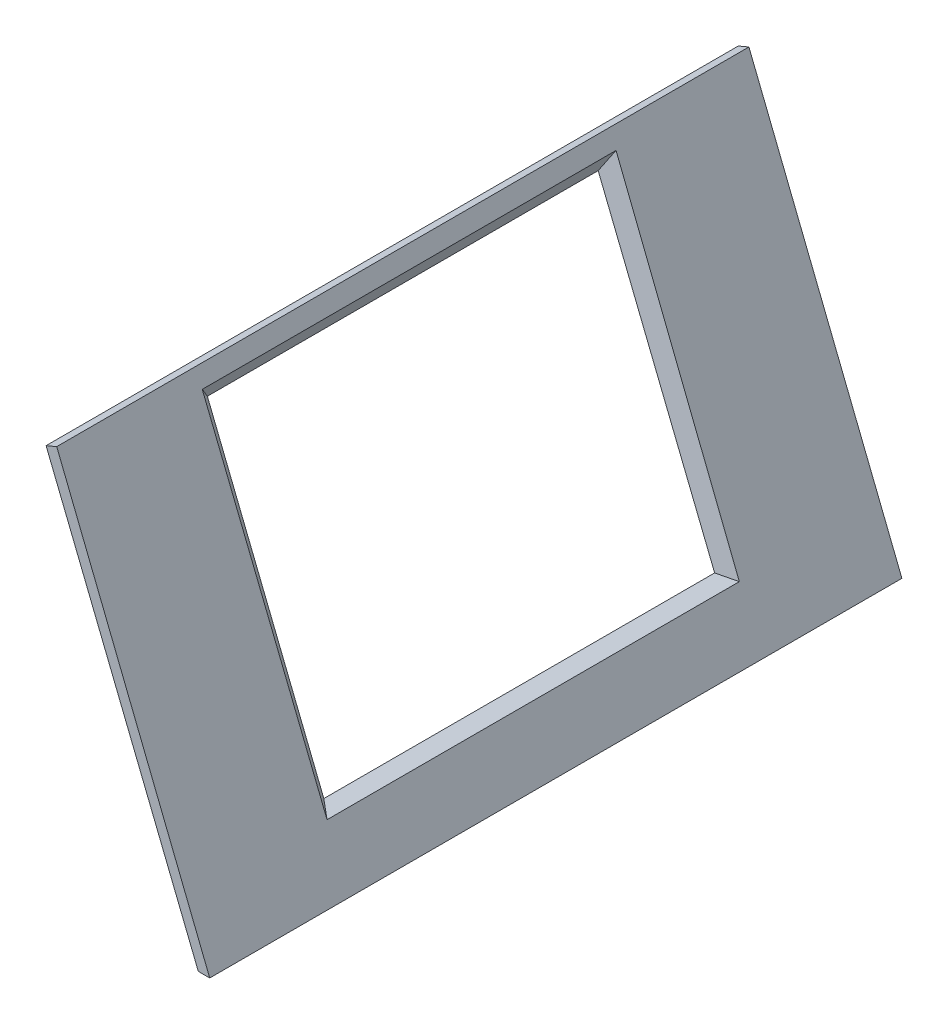
from build123d import *

# Parameters (mm, degrees)
BOSS_EXTRU_1_DEPTH      = 600
ESQUISSE2_W             = 338.746
ESQUISSE2_H             = 271
ENL_V_MAT_EXTRU_1_DEPTH = 10
ENL_V_MAT_EXTRU_1_TAPER = -45


with BuildPart() as part:
    # Esquisse1 → Boss.-Extru.1 (new body)
    with BuildSketch(Plane.XY):
        Polygon((235.606802378, 81.334991463), (103.65574387, 410.044643603), (112.874448857, 413.919624682), (245.500189591, 81.334991463), align=None)
    extrude(amount=BOSS_EXTRU_1_DEPTH)

    # Esquisse2 → Enlèv. mat.-Extru.1 (cut)
    with BuildSketch(Plane(origin=(231.028658646, 92.739826335, 0), x_dir=(0, 0, 1), z_dir=(-0.928021166, -0.37252747, 0))):
        with Locations((300.232670333, 181.16149611)):
            Rectangle(ESQUISSE2_W, ESQUISSE2_H)
    extrude(amount=-ENL_V_MAT_EXTRU_1_DEPTH, taper=ENL_V_MAT_EXTRU_1_TAPER, mode=Mode.SUBTRACT)


solid = part.part
